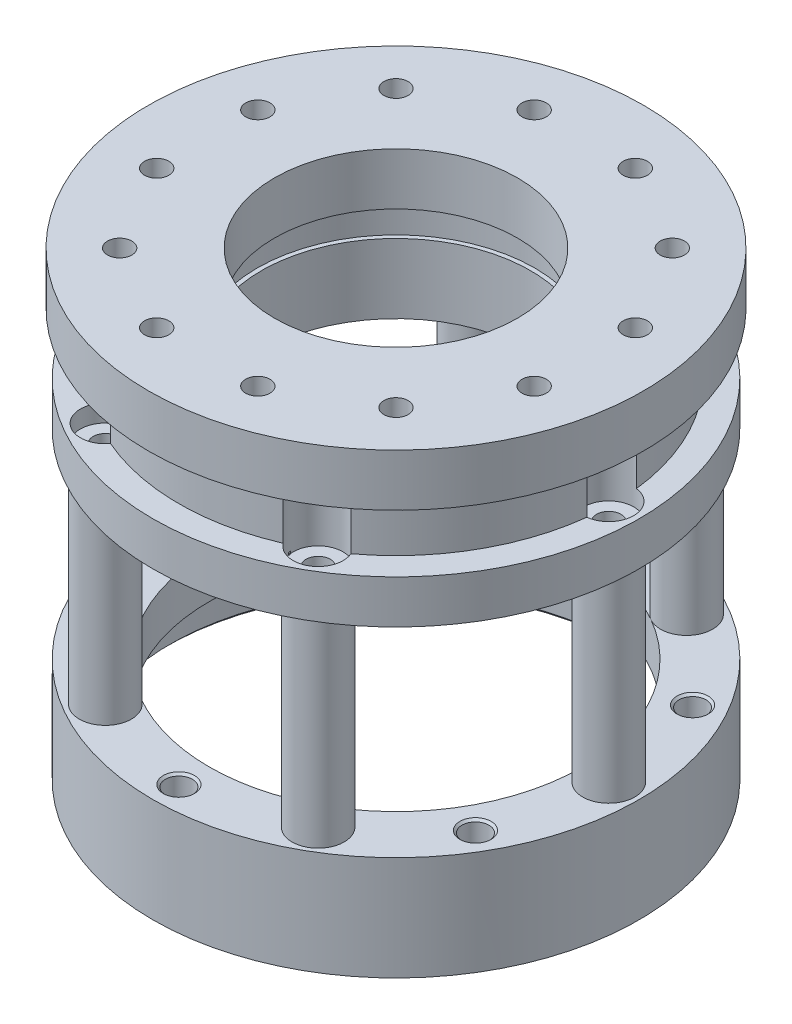
from build123d import *

# Parameters (mm, degrees)
SKETCH1_R                    = 3
BOSS_EXTRUDE1_DEPTH          = 23
CIRPATTERN1_COUNT            = 6
SKETCH3_R                    = 28
SKETCH3_R_2                  = 21.5
BOSS_EXTRUDE2_DEPTH          = 5
SKETCH4_R                    = 28
SKETCH4_R_2                  = 26
BOSS_EXTRUDE3_DEPTH          = 7
SKETCH5_R                    = 1.55
CUT_EXTRUDE1_DEPTH           = 4
CHAMFER1_SIZE                = 0.25
SKETCH6_R                    = 28
SKETCH6_R_2                  = 15.5
BOSS_EXTRUDE4_DEPTH          = 5
SKETCH7_R                    = 25
SKETCH7_R_2                  = 15.5
BOSS_EXTRUDE5_DEPTH          = 7
SKETCH8_R                    = 16
CUT_EXTRUDE2_DEPTH           = 4
SKETCH9_R                    = 1.55
CUT_EXTRUDE3_DEPTH           = 4.5
CHAMFER2_SIZE                = 0.25
CIRPATTERN2_COUNT            = 6
CHAMFER2_OF_CIRPATTERN2_SIZE = 0.25
SKETCH10_R                   = 28.5
SKETCH10_R_2                 = 14
BOSS_EXTRUDE6_DEPTH          = 6
CUT_EXTRUDE4_START           = -2
SKETCH11_R                   = 2.875
CUT_EXTRUDE4_DEPTH           = 9
SKETCH12_R                   = 1.4
CUT_EXTRUDE5_DEPTH           = 28
CIRPATTERN3_COUNT            = 6
CHAMFER3_SIZE                = 0.5
SKETCH13_R                   = 1.4
CUT_EXTRUDE6_DEPTH           = 16
CUT_EXTRUDE7_DEPTH           = 3.25
CHAMFER4_SIZE                = 0.5


with BuildPart() as part:
    # Sketch1 → Boss-Extrude1 (new body)
    with BuildSketch(Plane(origin=(0, 0, 0), x_dir=(1, 0, 0), z_dir=(0, 1, 0))):
        with Locations((24.5, 0)):
            Circle(SKETCH1_R)
    extrude(amount=BOSS_EXTRUDE1_DEPTH)


with BuildPart() as cirpattern1_1:
    # CirPattern1: pattern copy
    add(part.part.rotate(Axis((0, 0, 0), (0, 1, 0)), 1 * 360 / CIRPATTERN1_COUNT))


with BuildPart() as cirpattern1_2:
    # CirPattern1: pattern copy
    add(part.part.rotate(Axis((0, 0, 0), (0, 1, 0)), 2 * 360 / CIRPATTERN1_COUNT))


with BuildPart() as cirpattern1_3:
    # CirPattern1: pattern copy
    add(part.part.rotate(Axis((0, 0, 0), (0, 1, 0)), 3 * 360 / CIRPATTERN1_COUNT))


with BuildPart() as cirpattern1_4:
    # CirPattern1: pattern copy
    add(part.part.rotate(Axis((0, 0, 0), (0, 1, 0)), 4 * 360 / CIRPATTERN1_COUNT))


with BuildPart() as cirpattern1_5:
    # CirPattern1: pattern copy
    add(part.part.rotate(Axis((0, 0, 0), (0, 1, 0)), 5 * 360 / CIRPATTERN1_COUNT))


with BuildPart() as part_1:
    add(part.part)

    add(cirpattern1_1.part)  # Boss-Extrude2 merges CirPattern1_1

    add(cirpattern1_2.part)  # Boss-Extrude2 merges CirPattern1_2

    add(cirpattern1_3.part)  # Boss-Extrude2 merges CirPattern1_3

    add(cirpattern1_4.part)  # Boss-Extrude2 merges CirPattern1_4

    add(cirpattern1_5.part)  # Boss-Extrude2 merges CirPattern1_5
    # Sketch3 → Boss-Extrude2 (add)
    with BuildSketch(Plane(origin=(0, 0, 0), x_dir=(1, 0, 0), z_dir=(0, 1, 0))):
        Circle(SKETCH3_R)
        Circle(SKETCH3_R_2, mode=Mode.SUBTRACT)
    extrude(amount=-BOSS_EXTRUDE2_DEPTH)

    # Sketch4 → Boss-Extrude3 (add)
    with BuildSketch(Plane.XZ.offset(5)):
        Circle(SKETCH4_R)
        Circle(SKETCH4_R_2, mode=Mode.SUBTRACT)
    extrude(amount=BOSS_EXTRUDE3_DEPTH)

    # Sketch5 → Cut-Extrude1 (cut)
    with BuildSketch(Plane(origin=(0, 0, 0), x_dir=(1, 0, 0), z_dir=(0, 1, 0))):
        with Locations((21.650635095, -12.5)):
            Circle(SKETCH5_R)
        with Locations((0, -25)):
            Circle(SKETCH5_R)
        with Locations((-21.650635095, -12.5)):
            Circle(SKETCH5_R)
        with Locations((-21.650635095, 12.5)):
            Circle(SKETCH5_R)
        with Locations((0, 25)):
            Circle(SKETCH5_R)
        with Locations((21.650635095, 12.5)):
            Circle(SKETCH5_R)
    extrude(amount=-CUT_EXTRUDE1_DEPTH, mode=Mode.SUBTRACT)

    # Chamfer1
    chamfer1_edges = [part_1.edges().sort_by_distance(p)[0] for p in [
        (20.100635095, 0, -12.5),
        (-1.55, 0, -25),
        (-23.200635095, 0, -12.5),
        (-23.200635095, 0, 12.5),
        (-1.55, 0, 25),
        (20.100635095, 0, 12.5),
    ]]
    chamfer(chamfer1_edges, length=CHAMFER1_SIZE)


with BuildPart() as body_2:
    # Sketch6 → Boss-Extrude4 (new body)
    with BuildSketch(Plane(origin=(0, 23, 0), x_dir=(1, 0, 0), z_dir=(0, 1, 0))):
        Circle(SKETCH6_R)
        Circle(SKETCH6_R_2, mode=Mode.SUBTRACT)
    extrude(amount=BOSS_EXTRUDE4_DEPTH)

    # Sketch7 → Boss-Extrude5 (add)
    with BuildSketch(Plane(origin=(0, 28, 0), x_dir=(1, 0, 0), z_dir=(0, 1, 0))):
        Circle(SKETCH7_R)
        Circle(SKETCH7_R_2, mode=Mode.SUBTRACT)
    extrude(amount=BOSS_EXTRUDE5_DEPTH)

    # Sketch8 → Cut-Extrude2 (cut)
    with BuildSketch(Plane(origin=(0, 35, 0), x_dir=(1, 0, 0), z_dir=(0, 1, 0))):
        Circle(SKETCH8_R)
    extrude(amount=-CUT_EXTRUDE2_DEPTH, mode=Mode.SUBTRACT)

    # Sketch9 → Cut-Extrude3 (cut)
    with BuildSketch(Plane.XZ.offset(-23)):
        with Locations((21.650635095, 12.5)):
            Circle(SKETCH9_R)
    cut_extrude3 = extrude(amount=-CUT_EXTRUDE3_DEPTH, mode=Mode.SUBTRACT)

    # Chamfer2
    chamfer2_edges = [body_2.edges().sort_by_distance(p)[0] for p in [
        (20.100635095, 23, 12.5),
    ]]
    chamfer(chamfer2_edges, length=CHAMFER2_SIZE)

    # CirPattern2: Cut-Extrude3 ×6 about axis
    cirpattern2_axis = Axis((0, 0, 0), (0, 1, 0))
    for i in range(1, CIRPATTERN2_COUNT):
        add(cut_extrude3.rotate(cirpattern2_axis, i * 360 / CIRPATTERN2_COUNT), mode=Mode.SUBTRACT)

    # Chamfer2 of CirPattern2
    chamfer2_of_cirpattern2_edges = [body_2.edges().sort_by_distance(p)[0] for p in [
        (20.875635095, 23, -11.157660624),
        (0.775, 23, -23.657660624),
        (-20.100635095, 23, -12.5),
        (-20.875635095, 23, 11.157660624),
        (-0.775, 23, 23.657660624),
    ]]
    chamfer(chamfer2_of_cirpattern2_edges, length=CHAMFER2_OF_CIRPATTERN2_SIZE)

    # Sketch11 → Cut-Extrude4 (cut)
    with BuildSketch(Plane(origin=(0, 28, 0), x_dir=(1, 0, 0), z_dir=(0, 1, 0)).offset(CUT_EXTRUDE4_START)):
        with Locations((24.5, 0)):
            Circle(SKETCH11_R)
    cut_extrude4 = extrude(amount=CUT_EXTRUDE4_DEPTH, mode=Mode.SUBTRACT)


with BuildPart() as body_3:
    # Sketch10 → Boss-Extrude6 (new body)
    with BuildSketch(Plane(origin=(0, 35, 0), x_dir=(1, 0, 0), z_dir=(0, 1, 0))):
        Circle(SKETCH10_R)
        Circle(SKETCH10_R_2, mode=Mode.SUBTRACT)
    extrude(amount=BOSS_EXTRUDE6_DEPTH)


with BuildPart() as cut_extrude5_tool:
    # Sketch12 → Cut-Extrude5 (new body)
    with BuildSketch(Plane(origin=(0, 26, 0), x_dir=(1, 0, 0), z_dir=(0, 1, 0))):
        with Locations((24.5, 0)):
            Circle(SKETCH12_R)
    cut_extrude5 = extrude(amount=-CUT_EXTRUDE5_DEPTH)


with BuildPart() as part_2:
    add(part_1.part)

    # Cut-Extrude5: cut by cut_extrude5_tool
    add(cut_extrude5_tool.part, mode=Mode.SUBTRACT)


with BuildPart() as body_2_1:
    add(body_2.part)

    # Cut-Extrude5: cut by cut_extrude5_tool
    add(cut_extrude5_tool.part, mode=Mode.SUBTRACT)


with BuildPart() as cirpattern3_tool:
    # CirPattern3: Cut-Extrude4, Cut-Extrude5 ×6 about axis
    cirpattern3_axis = Axis((0, 0, 0), (0, 1, 0))
    for i in range(1, CIRPATTERN3_COUNT):
        add(cut_extrude4.rotate(cirpattern3_axis, i * 360 / CIRPATTERN3_COUNT))
        add(cut_extrude5.rotate(cirpattern3_axis, i * 360 / CIRPATTERN3_COUNT))


with BuildPart() as part_3:
    add(part_2.part)

    # CirPattern3: cut by cirpattern3_tool
    add(cirpattern3_tool.part, mode=Mode.SUBTRACT)

    # Chamfer3
    chamfer3_edges = [part_3.edges().sort_by_distance(p)[0] for p in [
        (-26, -12, 0),
    ]]
    chamfer(chamfer3_edges, length=CHAMFER3_SIZE)


with BuildPart() as body_2_2:
    add(body_2_1.part)

    # CirPattern3: cut by cirpattern3_tool
    add(cirpattern3_tool.part, mode=Mode.SUBTRACT)


with BuildPart() as cut_extrude6_tool:
    # Sketch13 → Cut-Extrude6 (new body)
    with BuildSketch(Plane(origin=(0, 41, 0), x_dir=(1, 0, 0), z_dir=(0, 1, 0))):
        with Locations((21.733331092, -5.823428515)):
            Circle(SKETCH13_R)
        with Locations((15.909902577, -15.909902577)):
            Circle(SKETCH13_R)
        with Locations((5.823428515, -21.733331092)):
            Circle(SKETCH13_R)
        with Locations((-5.823428515, -21.733331092)):
            Circle(SKETCH13_R)
        with Locations((-15.909902577, -15.909902577)):
            Circle(SKETCH13_R)
        with Locations((-21.733331092, -5.823428515)):
            Circle(SKETCH13_R)
        with Locations((-21.733331092, 5.823428515)):
            Circle(SKETCH13_R)
        with Locations((-15.909902577, 15.909902577)):
            Circle(SKETCH13_R)
        with Locations((-5.823428515, 21.733331092)):
            Circle(SKETCH13_R)
        with Locations((5.823428515, 21.733331092)):
            Circle(SKETCH13_R)
        with Locations((15.909902577, 15.909902577)):
            Circle(SKETCH13_R)
        with Locations((21.733331092, 5.823428515)):
            Circle(SKETCH13_R)
    extrude(amount=-CUT_EXTRUDE6_DEPTH)


with BuildPart() as body_2_3:
    add(body_2_2.part)

    # Cut-Extrude6: cut by cut_extrude6_tool
    add(cut_extrude6_tool.part, mode=Mode.SUBTRACT)

    # Sketch14 → Cut-Extrude7 (cut)
    with BuildSketch(Plane.XZ.offset(-23)):
        Polygon((24.908331092, -7.656515619), (24.908331092, -3.99034141), (21.733331092, -2.157254305), (18.558331092, -3.99034141), (18.558331092, -7.656515619), (21.733331092, -9.489602724), align=None)
        Polygon((25.399505301, 5.823428515), (23.566418196, 8.998428515), (19.900243987, 8.998428515), (18.067156882, 5.823428515), (19.900243987, 2.648428515), (23.566418196, 2.648428515), align=None)
        Polygon((17.742989681, -19.084902577), (19.576076786, -15.909902577), (17.742989681, -12.734902577), (14.076815472, -12.734902577), (12.243728367, -15.909902577), (14.076815472, -19.084902577), align=None)
        Polygon((5.823428515, -25.399505301), (8.998428515, -23.566418196), (8.998428515, -19.900243987), (5.823428515, -18.067156882), (2.648428515, -19.900243987), (2.648428515, -23.566418196), align=None)
        Polygon((-7.656515619, -24.908331092), (-3.99034141, -24.908331092), (-2.157254305, -21.733331092), (-3.99034141, -18.558331092), (-7.656515619, -18.558331092), (-9.489602724, -21.733331092), align=None)
        Polygon((-19.084902577, -17.742989681), (-15.909902577, -19.576076786), (-12.734902577, -17.742989681), (-12.734902577, -14.076815472), (-15.909902577, -12.243728367), (-19.084902577, -14.076815472), align=None)
        Polygon((-25.399505301, -5.823428515), (-23.566418196, -8.998428515), (-19.900243987, -8.998428515), (-18.067156882, -5.823428515), (-19.900243987, -2.648428515), (-23.566418196, -2.648428515), align=None)
        Polygon((-24.908331092, 7.656515619), (-24.908331092, 3.99034141), (-21.733331092, 2.157254305), (-18.558331092, 3.99034141), (-18.558331092, 7.656515619), (-21.733331092, 9.489602724), align=None)
        Polygon((-17.742989681, 19.084902577), (-19.576076786, 15.909902577), (-17.742989681, 12.734902577), (-14.076815472, 12.734902577), (-12.243728367, 15.909902577), (-14.076815472, 19.084902577), align=None)
        Polygon((-5.823428515, 25.399505301), (-8.998428515, 23.566418196), (-8.998428515, 19.900243987), (-5.823428515, 18.067156882), (-2.648428515, 19.900243987), (-2.648428515, 23.566418196), align=None)
        Polygon((7.656515619, 24.908331092), (3.99034141, 24.908331092), (2.157254305, 21.733331092), (3.99034141, 18.558331092), (7.656515619, 18.558331092), (9.489602724, 21.733331092), align=None)
        Polygon((19.084902577, 17.742989681), (15.909902577, 19.576076786), (12.734902577, 17.742989681), (12.734902577, 14.076815472), (15.909902577, 12.243728367), (19.084902577, 14.076815472), align=None)
    extrude(amount=-CUT_EXTRUDE7_DEPTH, mode=Mode.SUBTRACT)

    # Chamfer4
    chamfer4_edges = [body_2_3.edges().sort_by_distance(p)[0] for p in [
        (-16, 35, 0),
        (21.650635095, 35, -12.5),
        (0, 35, -25),
        (-21.650635095, 35, -12.5),
        (-21.650635095, 35, 12.5),
        (0, 35, 25),
        (21.650635095, 35, 12.5),
    ]]
    chamfer(chamfer4_edges, length=CHAMFER4_SIZE)


with BuildPart() as body_3_1:
    add(body_3.part)

    # Cut-Extrude6: cut by cut_extrude6_tool
    add(cut_extrude6_tool.part, mode=Mode.SUBTRACT)


solid = Compound([part_3.part, body_2_3.part, body_3_1.part])
